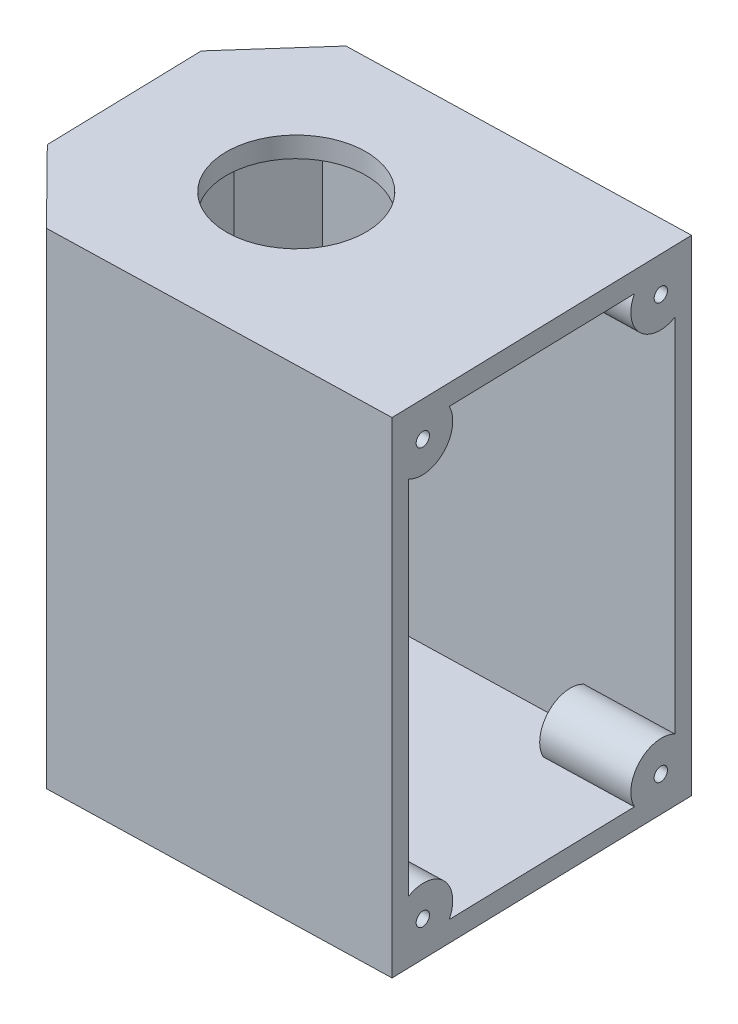
from build123d import *

# Parameters (mm, degrees)
SKETCH1_R                        = 4.951729289
BOSS_EXTRUDE3_DEPTH              = 3
BOSS_EXTRUDE4_DEPTH              = 68
SKETCH5_R                        = 4.5
CUT_EXTRUDE1_DEPTH               = 68
SKETCH11_W                       = 45.01572081
SKETCH11_H                       = 71
CUT_EXTRUDE3_DEPTH               = 2.5
SKETCH12_R                       = 13
BOSS_EXTRUDE7_DEPTH              = 3
SKETCH13_W                       = 45.01572081
SKETCH13_H                       = 71
CUT_EXTRUDE4_DEPTH               = 13
SKETCH14_W                       = 45.01572081
SKETCH14_H                       = 71
BOSS_EXTRUDE8_DEPTH              = 3
SKETCH15_R                       = 1.5
BOSS_EXTRUDE11_DEPTH             = 56.52620135
SKETCH16_R                       = 9
SKETCH16_R_2                     = 4.15
BOSS_EXTRUDE12_DEPTH             = 2
BOSS_EXTRUDE12_DIRECTION_2_REACH = 85.837
SKETCH17_R                       = 9
SKETCH17_R_2                     = 1
BOSS_EXTRUDE13_DEPTH             = 2
SKETCH18_R                       = 13
SKETCH18_R_2                     = 1
BOSS_EXTRUDE14_DEPTH             = 3
SKETCH19_R                       = 1.5
SKETCH19_R_2                     = 1
BOSS_EXTRUDE15_DEPTH             = 56.52620135
CUT_EXTRUDE9_DEPTH               = 43.52620135
SKETCH27_R                       = 10
SKETCH27_R_2                     = 1
CUT_EXTRUDE12_DEPTH              = 10
SKETCH28_R                       = 4.15
CUT_EXTRUDE13_DEPTH              = 73
SKETCH29_R                       = 4.5
SKETCH29_R_2                     = 4.15
CUT_EXTRUDE14_DEPTH              = 73
SKETCH30_R                       = 9
CUT_EXTRUDE15_DEPTH              = 4
SKETCH31_R                       = 10.2
CUT_EXTRUDE17_DEPTH              = 3
CUT_EXTRUDE18_DEPTH              = 197
SKETCH33_W                       = 14.992341928
SKETCH33_H                       = 71
BOSS_EXTRUDE16_DEPTH             = 1
SKETCH34_W                       = 14.992341928
SKETCH34_H                       = 71
BOSS_EXTRUDE17_DEPTH             = 1


with BuildPart() as part:
    # Sketch1 → Boss-Extrude3 (new body)
    with BuildSketch(Plane(origin=(0, 0, 0), x_dir=(1, 0, 0), z_dir=(0, 1, 0))):
        Polygon((-55.988214466, 21.072670098), (19.011785534, 23.055317054), (20.201373708, -21.944682946), (-54.798626292, -23.927329902), align=None)
        with Locations(Location((-17.893420379, -0.436006424, 0), (0, 0, 270))):
            Circle(SKETCH1_R, mode=Mode.SUBTRACT)
    extrude(amount=BOSS_EXTRUDE3_DEPTH)

    # Sketch4 → Boss-Extrude4 (add)
    with BuildSketch(Plane(origin=(0, 3, 0), x_dir=(1, 0, 0), z_dir=(0, 1, 0))):
        Polygon((-54.798626292, -23.927329902), (20.201373708, -21.944682946), (19.011785534, 23.055317054), (-55.988214466, 21.072670098), align=None)
        Polygon((-52.365564518, -21.362137824), (17.636181629, -19.511621172), (16.578723759, 20.490124975), (-53.423022387, 18.639608323), align=None, mode=Mode.SUBTRACT)
    extrude(amount=BOSS_EXTRUDE4_DEPTH)

    # Sketch5 → Cut-Extrude1 (cut)
    with BuildSketch(Plane(origin=(19.607557344, 0, -0.518331518), x_dir=(-0.026426060768931774, 0, -0.9996507706755579), z_dir=(0.999650770675558, 0, -0.026426060768931777))):
        with Locations((0.036998456, 35.5)):
            Circle(SKETCH5_R)
        with BuildLine():
            ThreePointArc((-17.463001544, 29.25), (-19.213001544, 27.5), (-17.463001544, 25.75))
            ThreePointArc((-17.463001544, 25.75), (-15.713001544, 27.5), (-17.463001544, 29.25))
        make_face()
        with BuildLine():
            ThreePointArc((17.536998456, 25.75), (19.286998456, 27.5), (17.536998456, 29.25))
            ThreePointArc((17.536998456, 29.25), (15.786998456, 27.5), (17.536998456, 25.75))
        make_face()
    extrude(amount=-CUT_EXTRUDE1_DEPTH, mode=Mode.SUBTRACT)

    # Sketch11 → Cut-Extrude3 (cut)
    with BuildSketch(Plane(origin=(19.607557344, 0, -0.518331518), x_dir=(-0.026426060768931756, 0, -0.9996507706755579), z_dir=(0.999650770675558, 0, -0.02642606076893176))):
        with Locations((0.036998456, 35.5)):
            Rectangle(SKETCH11_W, SKETCH11_H)
    extrude(amount=-CUT_EXTRUDE3_DEPTH, mode=Mode.SUBTRACT)

    # Sketch12 → Boss-Extrude7 (add)
    with BuildSketch(Plane(origin=(0, 71, 0), x_dir=(1, 0, 0), z_dir=(0, 1, 0))):
        Polygon((17.636181629, -19.511621172), (16.578723759, 20.490124975), (-53.423022387, 18.639608323), (-52.365564518, -21.362137824), align=None)
        with Locations(Location((-17.893420379, -0.436006424, 0), (0, 0, 270))):
            Circle(SKETCH12_R, mode=Mode.SUBTRACT)
    extrude(amount=-BOSS_EXTRUDE7_DEPTH)

    # Sketch13 → Cut-Extrude4 (cut)
    with BuildSketch(Plane(origin=(-55.392442656, 0, 1.464315438), x_dir=(0.02642606076893168, 0, 0.9996507706755579), z_dir=(-0.999650770675558, 0, 0.026426060768931683))):
        with Locations((-0.036998456, 35.5)):
            Rectangle(SKETCH13_W, SKETCH13_H)
    extrude(amount=-CUT_EXTRUDE4_DEPTH, mode=Mode.SUBTRACT)

    # Sketch14 → Boss-Extrude8 (add)
    with BuildSketch(Plane(origin=(-42.396982637, 0, 1.120776648), x_dir=(0.026426060768931694, 0, 0.9996507706755579), z_dir=(-0.999650770675558, 0, 0.026426060768931697))):
        with Locations((-0.036998456, 35.5)):
            Rectangle(SKETCH14_W, SKETCH14_H)
    extrude(amount=-BOSS_EXTRUDE8_DEPTH)

    # Sketch15 → Boss-Extrude11 (add)
    with BuildSketch(Plane(origin=(17.108430418, 0, -0.452266367), x_dir=(-0.02642606076893177, 0, -0.9996507706755579), z_dir=(0.999650770675558, 0, -0.026426060768931774))):
        with BuildLine():
            ThreePointArc((20.044858861, 9.08994731), (14.741558002, 8.303300859), (13.954911551, 3))
            Line((13.954911551, 3), (20.044858861, 3))
            Line((20.044858861, 3), (20.044858861, 9.08994731))
        make_face()
        with Locations((17.923538517, 5.121320344)):
            Circle(SKETCH15_R, mode=Mode.SUBTRACT)
        with BuildLine():
            Line((-19.970861949, 9.08994731), (-19.970861949, 3))
            Line((-19.970861949, 3), (-13.880914639, 3))
            ThreePointArc((-13.880914639, 3), (-14.66756109, 8.303300859), (-19.970861949, 9.08994731))
        make_face()
        with Locations((-17.849541605, 5.121320344)):
            Circle(SKETCH15_R, mode=Mode.SUBTRACT)
        with BuildLine():
            Line((20.044858861, 68), (13.954911551, 68))
            ThreePointArc((13.954911551, 68), (14.741558002, 62.696699141), (20.044858861, 61.91005269))
            Line((20.044858861, 61.91005269), (20.044858861, 68))
        make_face()
        with Locations((17.923538517, 65.878679656)):
            Circle(SKETCH15_R, mode=Mode.SUBTRACT)
        with BuildLine():
            Line((-19.970861949, 68), (-19.970861949, 61.91005269))
            ThreePointArc((-19.970861949, 61.91005269), (-14.66756109, 62.696699141), (-13.880914639, 68))
            Line((-13.880914639, 68), (-19.970861949, 68))
        make_face()
        with Locations((-17.849541605, 65.878679656)):
            Circle(SKETCH15_R, mode=Mode.SUBTRACT)
    extrude(amount=-BOSS_EXTRUDE11_DEPTH)

    # Sketch16 → Boss-Extrude12 (add)
    with BuildSketch(Plane(origin=(0, 3, 0), x_dir=(1, 0, 0), z_dir=(0, 1, 0))):
        with Locations(Location((-17.893420379, -0.436006424, 0), (0, 0, 270))):
            Circle(SKETCH16_R)
        with Locations(Location((-17.893420379, -0.436006424, 0), (0, 0, 270))):
            Circle(SKETCH16_R_2, mode=Mode.SUBTRACT)
    extrude(amount=BOSS_EXTRUDE12_DEPTH)

    # Boss-Extrude12 direction 2: up to this face of the body (flat: up to its plane)
    boss_extrude12_direction_2_end = Plane(part.part.faces().sort_by_distance((-12.489919849, 0, 0.293163306))[0])
    # Sketch16 → Boss-Extrude12 direction 2 (add, up to the picked face)
    with BuildSketch(Plane(origin=(0, 3, 0), x_dir=(1, 0, 0), z_dir=(0, 1, 0)), mode=Mode.PRIVATE) as boss_extrude12_direction_2_sk1:
        with Locations(Location((-17.893420379, -0.436006424, 0), (0, 0, 270))):
            Circle(SKETCH16_R)
        with Locations(Location((-17.893420379, -0.436006424, 0), (0, 0, 270))):
            Circle(SKETCH16_R_2, mode=Mode.SUBTRACT)
    boss_extrude12_direction_2_tool1 = split(extrude(boss_extrude12_direction_2_sk1.sketch, amount=-BOSS_EXTRUDE12_DIRECTION_2_REACH, mode=Mode.PRIVATE), bisect_by=boss_extrude12_direction_2_end, keep=Keep.BOTH, mode=Mode.PRIVATE)
    add(boss_extrude12_direction_2_tool1.solids().sort_by(Axis((-17.89342, 3, -8.309435), (0, -1, 0)))[0])

    # Sketch17 → Boss-Extrude13 (add)
    with BuildSketch(Plane(origin=(0, 5, 0), x_dir=(1, 0, 0), z_dir=(0, 1, 0))):
        with Locations(Location((-17.893420379, -0.436006424, 0), (0, 0, 270))):
            Circle(SKETCH17_R)
        with Locations(Location((-17.893420379, -0.436006424, 0), (0, 0, 270))):
            Circle(SKETCH17_R_2, mode=Mode.SUBTRACT)
    extrude(amount=BOSS_EXTRUDE13_DEPTH)

    # Sketch18 → Boss-Extrude14 (add)
    with BuildSketch(Plane(origin=(0, 71, 0), x_dir=(1, 0, 0), z_dir=(0, 1, 0))):
        with Locations((-17.893420379, -0.436006424)):
            Circle(SKETCH18_R)
        with Locations(Location((-17.893420379, -0.436006424, 0), (0, 0, 270))):
            Circle(SKETCH18_R_2, mode=Mode.SUBTRACT)
    extrude(amount=-BOSS_EXTRUDE14_DEPTH)

    # Sketch19 → Boss-Extrude15 (add)
    with BuildSketch(Plane(origin=(17.108430418, 0, -0.452266367), x_dir=(-0.02642606076893177, 0, -0.9996507706755579), z_dir=(0.999650770675558, 0, -0.026426060768931774))):
        with Locations((-17.849541605, 5.121320344)):
            Circle(SKETCH19_R)
        with Locations((-17.849541605, 5.121320344)):
            Circle(SKETCH19_R_2, mode=Mode.SUBTRACT)
        with Locations((17.923538517, 5.121320344)):
            Circle(SKETCH19_R)
        with Locations((17.923538517, 5.121320344)):
            Circle(SKETCH19_R_2, mode=Mode.SUBTRACT)
        with Locations((-17.849541605, 65.878679656)):
            Circle(SKETCH19_R)
        with Locations((-17.849541605, 65.878679656)):
            Circle(SKETCH19_R_2, mode=Mode.SUBTRACT)
        with Locations((17.923538517, 65.878679656)):
            Circle(SKETCH19_R)
        with Locations((17.923538517, 65.878679656)):
            Circle(SKETCH19_R_2, mode=Mode.SUBTRACT)
    extrude(amount=-BOSS_EXTRUDE15_DEPTH)

    # Sketch23 → Cut-Extrude9 (cut)
    with BuildSketch(Plane(origin=(4.112970399, 0, -0.108727577), x_dir=(-0.02642606076893177, 0, -0.9996507706755579), z_dir=(0.999650770675558, 0, -0.026426060768931774))):
        Polygon((-19.970861949, 68), (-19.970861949, 9.08994731), (-19.970861949, 3), (-13.880914639, 3), (-8.963001544, 3), (-8.963001544, 7), (9.036998456, 7), (9.036998456, 3), (20.044858861, 3), (20.044858861, 9.08994731), (20.044858861, 68), (-13.880914639, 68), align=None)
    extrude(amount=-CUT_EXTRUDE9_DEPTH, mode=Mode.SUBTRACT)

    # Sketch27 → Cut-Extrude12 (cut)
    with BuildSketch(Plane(origin=(0, 71, 0), x_dir=(1, 0, 0), z_dir=(0, 1, 0))):
        with Locations(Location((-17.893420379, -0.436006424, 0), (0, 0, 270))):
            Circle(SKETCH27_R)
        with Locations(Location((-17.893420379, -0.436006424, 0), (0, 0, 270))):
            Circle(SKETCH27_R_2, mode=Mode.SUBTRACT)
    extrude(amount=-CUT_EXTRUDE12_DEPTH, mode=Mode.SUBTRACT)

    # Sketch28 → Cut-Extrude13 (cut)
    with BuildSketch(Plane.XZ):
        with Locations(Location((-17.893420379, 0.436006424, 0), (0, 0, 90))):
            Circle(SKETCH28_R)
    extrude(amount=-CUT_EXTRUDE13_DEPTH, mode=Mode.SUBTRACT)

    # Sketch29 → Cut-Extrude14 (cut)
    with BuildSketch(Plane.XZ):
        with Locations(Location((-17.893420379, 0.436006424, 0), (0, 0, 270))):
            Circle(SKETCH29_R)
        with Locations((-17.893420379, 0.436006424)):
            Circle(SKETCH29_R_2, mode=Mode.SUBTRACT)
    extrude(amount=-CUT_EXTRUDE14_DEPTH, mode=Mode.SUBTRACT)

    # Sketch30 → Cut-Extrude15 (cut)
    with BuildSketch(Plane(origin=(0, 7, 0), x_dir=(1, 0, 0), z_dir=(0, 1, 0))):
        with Locations((-17.893420379, -0.436006424)):
            Circle(SKETCH30_R)
    extrude(amount=-CUT_EXTRUDE15_DEPTH, mode=Mode.SUBTRACT)

    # Sketch31 → Cut-Extrude17 (cut)
    with BuildSketch(Plane(origin=(0, 71, 0), x_dir=(1, 0, 0), z_dir=(0, 1, 0))):
        with Locations(Location((-17.893420379, -0.436006424, 0), (0, 0, 270))):
            Circle(SKETCH31_R)
    extrude(amount=-CUT_EXTRUDE17_DEPTH, mode=Mode.SUBTRACT)

    # Sketch32 → Cut-Extrude18 (cut)
    with BuildSketch(Plane(origin=(0, 71, 0), x_dir=(1, 0, 0), z_dir=(0, 1, 0))):
        Polygon((-42.992754447, 21.416208888), (-42.703678037, 10.480963623), (-32.74415639, 21.687133577), align=None)
        Polygon((-31.554568217, -23.312866423), (-42.092242683, -12.648545848), (-41.803166274, -23.583791112), align=None)
    extrude(amount=-CUT_EXTRUDE18_DEPTH, mode=Mode.SUBTRACT)

    # Sketch33 → Boss-Extrude16 (add)
    with BuildSketch(Plane(origin=(-27.621364057, 0, 27.293341448), x_dir=(0.7028704732937463, 0, 0.7113178598712571), z_dir=(-0.7113178598712571, 0, 0.7028704732937463))):
        with Locations((-13.09208701, 35.5)):
            Rectangle(SKETCH33_W, SKETCH33_H)
    extrude(amount=-BOSS_EXTRUDE16_DEPTH)

    # Sketch34 → Boss-Extrude17 (add)
    with BuildSketch(Plane(origin=(-29.062615571, 0, -25.829498399), x_dir=(-0.6643072639922937, 0, 0.7474596035954538), z_dir=(-0.7474596035954538, 0, -0.6643072639922937))):
        with Locations((13.038095641, 35.5)):
            Rectangle(SKETCH34_W, SKETCH34_H)
    extrude(amount=-BOSS_EXTRUDE17_DEPTH)


solid = part.part
